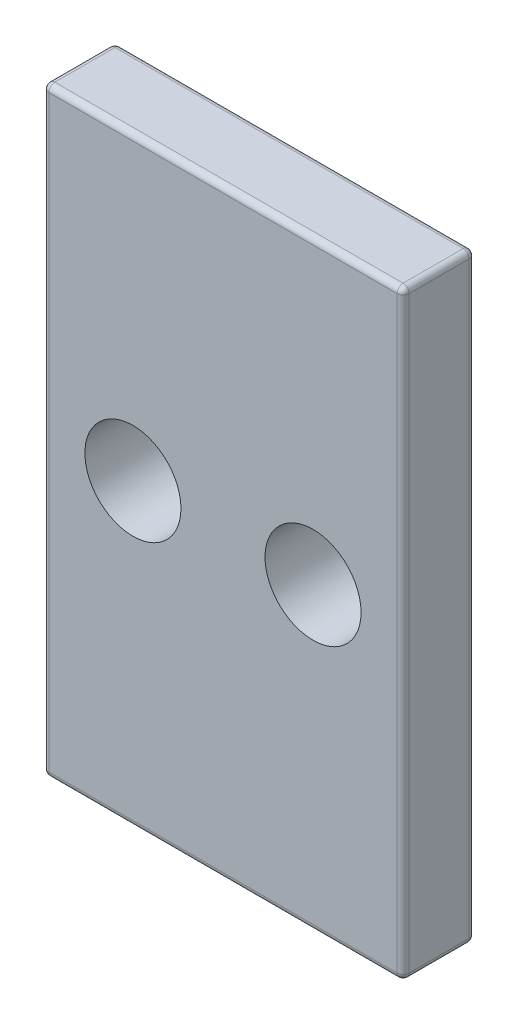
from build123d import *

# Parameters (mm, degrees)
SKETCH1_W           = 30
SKETCH1_H           = 50
SKETCH1_R           = 4
BOSS_EXTRUDE1_DEPTH = 6
FILLET1_R           = 0.5


with BuildPart() as part:
    # Sketch1 → Boss-Extrude1 (new body)
    with BuildSketch(Plane.XY):
        Rectangle(SKETCH1_W, SKETCH1_H)
        with Locations((-7.5, 0)):
            Circle(SKETCH1_R, mode=Mode.SUBTRACT)
        with Locations((7.5, 0)):
            Circle(SKETCH1_R, mode=Mode.SUBTRACT)
    extrude(amount=BOSS_EXTRUDE1_DEPTH)

    # Fillet1
    fillet1_edges = [part.edges().sort_by_distance(p)[0] for p in [
        (-15, 0, 6),
        (0, -25, 6),
        (15, 0, 6),
        (0, -25, 0),
        (-15, 0, 0),
        (0, 25, 0),
        (15, 0, 0),
        (15, -25, 3),
        (-15, -25, 3),
        (-15, 25, 3),
        (15, 25, 3),
        (0, 25, 6),
    ]]
    fillet(fillet1_edges, radius=FILLET1_R)


solid = part.part
